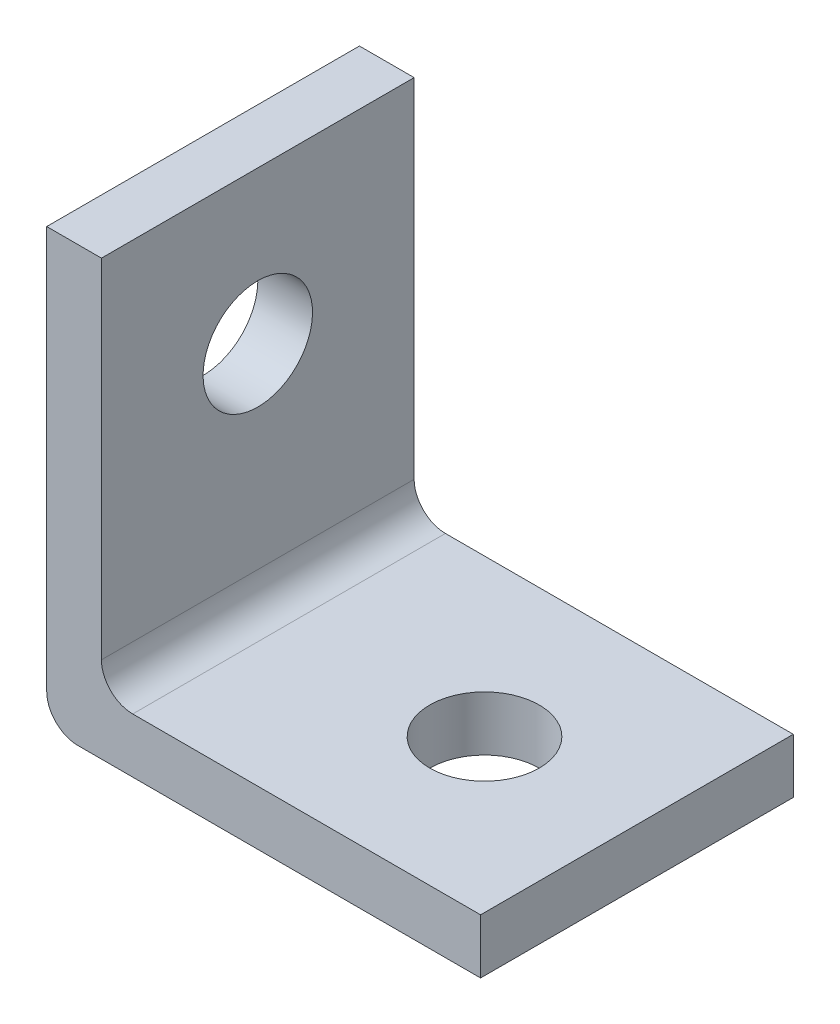
from build123d import *

# Parameters (mm, degrees)
BOSS_EXTRUDE1_DEPTH = 20
SKETCH2_R           = 3.5
CUT_EXTRUDE1_DEPTH  = 4.5
SKETCH3_R           = 3.5
CUT_EXTRUDE2_DEPTH  = 4.5
SKETCH4_W           = 22.25
SKETCH4_H           = 20
CUT_EXTRUDE3_DEPTH  = 4.5
SKETCH5_W           = 20
SKETCH5_H           = 22.25
CUT_EXTRUDE4_DEPTH  = 4.5


with BuildPart() as part:
    # Sketch1 → Boss-Extrude1 (new body)
    with BuildSketch(Plane.XY):
        with BuildLine():
            Line((0, 2), (0, 50))
            Line((0, 50), (3.5, 50))
            Line((3.5, 50), (3.5, 5.5))
            ThreePointArc((3.5, 5.5), (4.085786438, 4.085786438), (5.5, 3.5))
            Line((5.5, 3.5), (50, 3.5))
            Line((50, 3.5), (50, 0))
            Line((50, 0), (2, 0))
            ThreePointArc((2, 0), (0.585786438, 0.585786438), (0, 2))
        make_face()
    extrude(amount=BOSS_EXTRUDE1_DEPTH)

    # Sketch2 → Cut-Extrude1 (cut, through all)
    with BuildSketch(Plane(origin=(0, 3.5, 0), x_dir=(1, 0, 0), z_dir=(0, 1, 0))):
        with Locations((38, -10)):
            Circle(SKETCH2_R)
        with Locations((18, -10)):
            Circle(SKETCH2_R)
    extrude(amount=-CUT_EXTRUDE1_DEPTH, mode=Mode.SUBTRACT)

    # Sketch3 → Cut-Extrude2 (cut, through all)
    with BuildSketch(Plane(origin=(3.5, 0, 0), x_dir=(0, 0, -1), z_dir=(1, 0, 0))):
        with Locations((-10, 38)):
            Circle(SKETCH3_R)
        with Locations((-10, 18)):
            Circle(SKETCH3_R)
    extrude(amount=-CUT_EXTRUDE2_DEPTH, mode=Mode.SUBTRACT)

    # Sketch4 → Cut-Extrude3 (cut, through all)
    with BuildSketch(Plane(origin=(0, 3.5, 0), x_dir=(1, 0, 0), z_dir=(0, 1, 0))):
        with Locations((38.875, -10)):
            Rectangle(SKETCH4_W, SKETCH4_H)
    extrude(amount=-CUT_EXTRUDE3_DEPTH, mode=Mode.SUBTRACT)

    # Sketch5 → Cut-Extrude4 (cut, through all)
    with BuildSketch(Plane(origin=(3.5, 0, 0), x_dir=(0, 0, -1), z_dir=(1, 0, 0))):
        with Locations((-10, 38.875)):
            Rectangle(SKETCH5_W, SKETCH5_H)
    extrude(amount=-CUT_EXTRUDE4_DEPTH, mode=Mode.SUBTRACT)


solid = part.part
